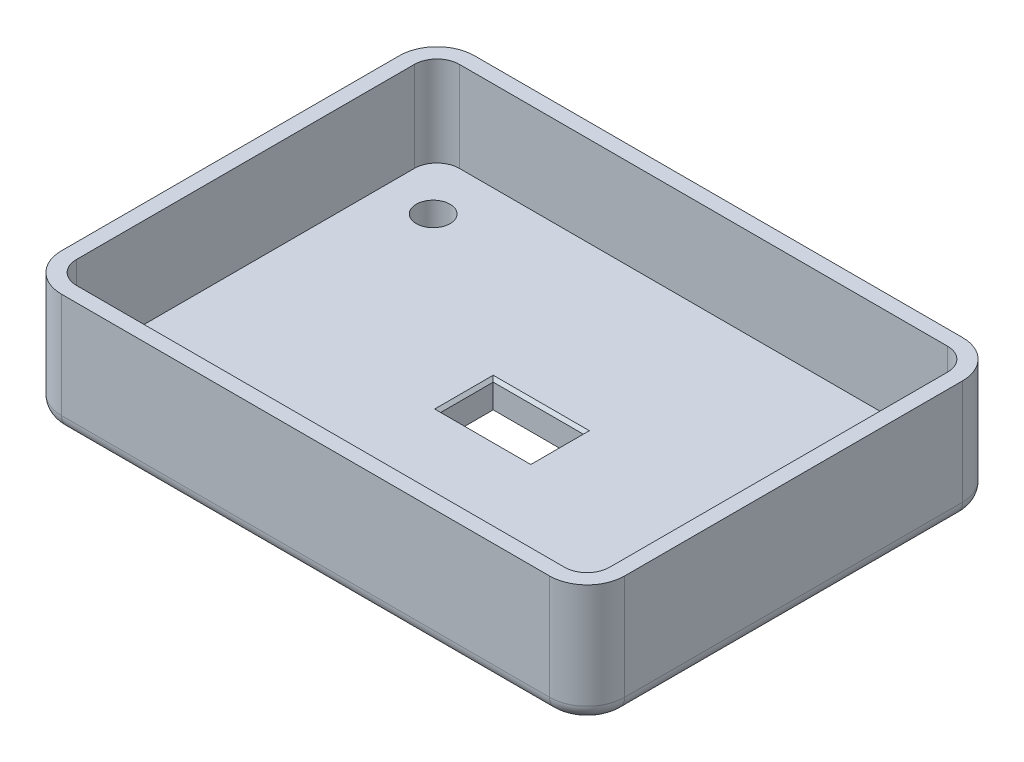
from build123d import *

# Parameters (mm, degrees)
SKETCH1_W           = 75
SKETCH1_H           = 55
BOSS_EXTRUDE1_DEPTH = 4
SKETCH2_W           = 75
SKETCH2_H           = 55
SKETCH2_W_2         = 71
SKETCH2_H_2         = 51
BOSS_EXTRUDE2_DEPTH = 12
SKETCH3_R           = 2.25
SKETCH3_W           = 12
SKETCH3_H           = 7
CUT_EXTRUDE1_DEPTH  = 5
FILLET1_R           = 5
FILLET2_R           = 3
FILLET3_R           = 2
CHAMFER1_SIZE       = 0.4


with BuildPart() as part:
    # Sketch1 → Boss-Extrude1 (new body)
    with BuildSketch(Plane(origin=(0, 0, 0), x_dir=(1, 0, 0), z_dir=(0, 1, 0))):
        Rectangle(SKETCH1_W, SKETCH1_H)
    extrude(amount=BOSS_EXTRUDE1_DEPTH)

    # Sketch2 → Boss-Extrude2 (add)
    with BuildSketch(Plane(origin=(0, 4, 0), x_dir=(1, 0, 0), z_dir=(0, 1, 0))):
        Rectangle(SKETCH2_W, SKETCH2_H)
        Rectangle(SKETCH2_W_2, SKETCH2_H_2, mode=Mode.SUBTRACT)
    extrude(amount=BOSS_EXTRUDE2_DEPTH)

    # Sketch3 → Cut-Extrude1 (cut, through all)
    with BuildSketch(Plane(origin=(0, 4, 0), x_dir=(1, 0, 0), z_dir=(0, 1, 0))):
        with Locations((-29, 18.5)):
            Circle(SKETCH3_R)
        with Locations((29, 18.5)):
            Circle(SKETCH3_R)
        with Locations((29, -18.5)):
            Circle(SKETCH3_R)
        with Locations((-29, -18.5)):
            Circle(SKETCH3_R)
        Rectangle(SKETCH3_W, SKETCH3_H)
    extrude(amount=-CUT_EXTRUDE1_DEPTH, mode=Mode.SUBTRACT)

    # Fillet1
    fillet1_edges = [part.edges().sort_by_distance(p)[0] for p in [
        (37.5, 8, 27.5),
        (-37.5, 8, 27.5),
        (-37.5, 8, -27.5),
        (37.5, 8, -27.5),
    ]]
    fillet(fillet1_edges, radius=FILLET1_R)

    # Fillet2
    fillet2_edges = [part.edges().sort_by_distance(p)[0] for p in [
        (35.5, 10, -25.5),
        (-35.5, 10, -25.5),
        (-35.5, 10, 25.5),
        (35.5, 10, 25.5),
    ]]
    fillet(fillet2_edges, radius=FILLET2_R)

    # Fillet3
    fillet3_edges = [part.edges().sort_by_distance(p)[0] for p in [
        (-37.5, 0, 0),
        (37.5, 0, 0),
        (0, 0, 27.5),
        (0, 0, -27.5),
        (-36.035533906, 0, 26.035533906),
        (36.035533906, 0, 26.035533906),
        (36.035533906, 0, -26.035533906),
        (-36.035533906, 0, -26.035533906),
    ]]
    fillet(fillet3_edges, radius=FILLET3_R)

    # Chamfer1
    chamfer1_edges = [part.edges().sort_by_distance(p)[0] for p in [
        (6, 0, 0),
        (0, 0, 3.5),
        (-6, 0, 0),
        (0, 0, -3.5),
        (6, 4, 0),
        (0, 4, -3.5),
        (-6, 4, 0),
        (0, 4, 3.5),
        (-31.25, 0, 18.5),
        (26.75, 0, 18.5),
        (26.75, 0, -18.5),
        (-31.25, 0, -18.5),
    ]]
    chamfer(chamfer1_edges, length=CHAMFER1_SIZE)


solid = part.part
